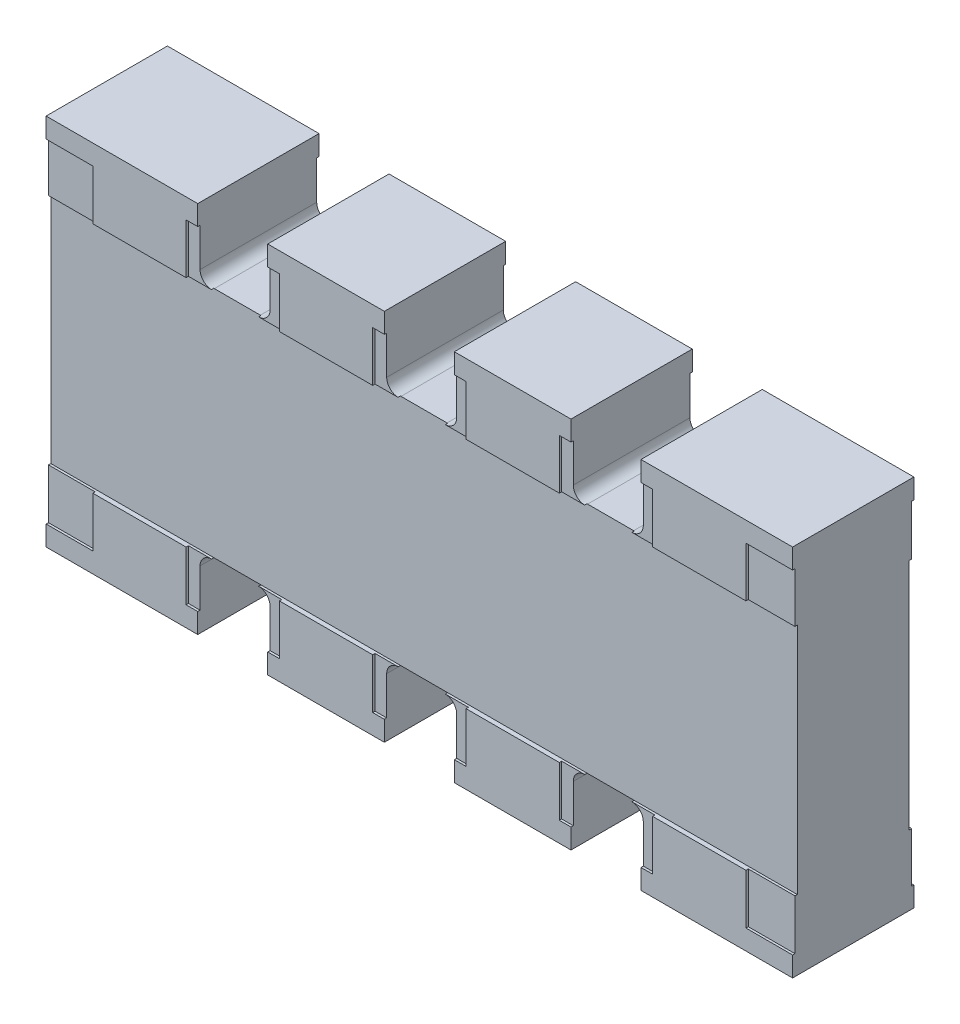
from build123d import *

# Parameters (mm, degrees)
SKETCH1_W           = 3.2
SKETCH1_H           = 1.6
BOSS_EXTRUDE1_DEPTH = 0.5
CUT_EXTRUDE1_DEPTH  = 1.5
SKETCH3_W           = 3.2
SKETCH3_H           = 1
CUT_EXTRUDE2_DEPTH  = 0.01
BOSS_EXTRUDE2_DEPTH = 0.01


with BuildPart() as part:
    # Sketch1 → Boss-Extrude1 (new body)
    with BuildSketch(Plane.XY):
        Rectangle(SKETCH1_W, SKETCH1_H)
    extrude(amount=BOSS_EXTRUDE1_DEPTH)

    # Sketch2 → Cut-Extrude1 (cut, through all)
    with BuildSketch(Plane(origin=(0, 0, 0), x_dir=(-1, 0, 0), z_dir=(0, 0, -1))):
        with BuildLine():
            Line((-0.15, 0.8), (0.15, 0.8))
            Line((0.15, 0.8), (0.15, 0.549979938))
            ThreePointArc((0.15, 0.549979938), (0.134862042, 0.514138446), (0.098614632, 0.5))
            Line((0.098614632, 0.5), (-0.098614632, 0.5))
            ThreePointArc((-0.098614632, 0.5), (-0.134862042, 0.514138446), (-0.15, 0.549979938))
            Line((-0.15, 0.549979938), (-0.15, 0.8))
        make_face()
        with BuildLine():
            Line((-0.65, 0.8), (-0.65, 0.549979938))
            ThreePointArc((-0.65, 0.549979938), (-0.665137958, 0.514138446), (-0.701385368, 0.5))
            Line((-0.701385368, 0.5), (-0.898614632, 0.5))
            ThreePointArc((-0.898614632, 0.5), (-0.934862042, 0.514138446), (-0.95, 0.549979938))
            Line((-0.95, 0.549979938), (-0.95, 0.8))
            Line((-0.95, 0.8), (-0.65, 0.8))
        make_face()
        with BuildLine():
            Line((0.95, 0.8), (0.65, 0.8))
            Line((0.65, 0.8), (0.65, 0.549979938))
            ThreePointArc((0.65, 0.549979938), (0.665137958, 0.514138446), (0.701385368, 0.5))
            Line((0.701385368, 0.5), (0.898614632, 0.5))
            ThreePointArc((0.898614632, 0.5), (0.934862042, 0.514138446), (0.95, 0.549979938))
            Line((0.95, 0.549979938), (0.95, 0.8))
        make_face()
        with BuildLine():
            Line((0.65, -0.8), (0.65, -0.549979938))
            ThreePointArc((0.65, -0.549979938), (0.665137958, -0.514138446), (0.701385368, -0.5))
            Line((0.701385368, -0.5), (0.898614632, -0.5))
            ThreePointArc((0.898614632, -0.5), (0.934862042, -0.514138446), (0.95, -0.549979938))
            Line((0.95, -0.549979938), (0.95, -0.8))
            Line((0.95, -0.8), (0.65, -0.8))
        make_face()
        with BuildLine():
            Line((0.15, -0.8), (0.15, -0.549979938))
            ThreePointArc((0.15, -0.549979938), (0.134862042, -0.514138446), (0.098614632, -0.5))
            Line((0.098614632, -0.5), (-0.098614632, -0.5))
            ThreePointArc((-0.098614632, -0.5), (-0.134862042, -0.514138446), (-0.15, -0.549979938))
            Line((-0.15, -0.549979938), (-0.15, -0.8))
            Line((-0.15, -0.8), (0.15, -0.8))
        make_face()
        with BuildLine():
            Line((-0.95, -0.8), (-0.65, -0.8))
            Line((-0.65, -0.8), (-0.65, -0.549979938))
            ThreePointArc((-0.65, -0.549979938), (-0.665137958, -0.514138446), (-0.701385368, -0.5))
            Line((-0.701385368, -0.5), (-0.898614632, -0.5))
            ThreePointArc((-0.898614632, -0.5), (-0.934862042, -0.514138446), (-0.95, -0.549979938))
            Line((-0.95, -0.549979938), (-0.95, -0.8))
        make_face()
    extrude(amount=-CUT_EXTRUDE1_DEPTH, mode=Mode.SUBTRACT)

    # Sketch3 → Cut-Extrude2 (cut)
    with BuildSketch(Plane(origin=(0, 0, 0), x_dir=(-1, 0, 0), z_dir=(0, 0, -1))):
        Rectangle(SKETCH3_W, SKETCH3_H)
    cut_extrude2 = extrude(amount=-CUT_EXTRUDE2_DEPTH, mode=Mode.SUBTRACT)

    # Mirror1: Cut-Extrude2 across plane
    add(cut_extrude2.mirror(Plane(origin=(0, 0, 0.25), x_dir=(1, 0, 0), z_dir=(0, 0, -1))), mode=Mode.SUBTRACT)

    # Sketch4 → Boss-Extrude2 (add)
    with BuildSketch(Plane(origin=(0, 0, 0), x_dir=(-1, 0, 0), z_dir=(0, 0, -1))):
        Polygon((-0.65, 0.71450836), (-0.6, 0.71450836), (-0.6, 0.5), (-0.2, 0.5), (-0.2, 0.71450836), (-0.15, 0.71450836), (-0.15, 0.8), (-0.65, 0.8), align=None)
        Polygon((-1.45, 0.71450836), (-1.4, 0.71450836), (-1.4, 0.5), (-1, 0.5), (-1, 0.71450836), (-0.95, 0.71450836), (-0.95, 0.8), (-1.45, 0.8), (-1.6, 0.8), (-1.6, 0.71450836), align=None)
        Polygon((1.6, 0.8), (1.6, 0.71450836), (1.45, 0.71450836), (1.4, 0.71450836), (1.4, 0.5), (1, 0.5), (1, 0.71450836), (0.95, 0.71450836), (0.95, 0.8), (1.45, 0.8), align=None)
        Polygon((0.6, 0.5), (0.2, 0.5), (0.2, 0.71450836), (0.15, 0.71450836), (0.15, 0.8), (0.65, 0.8), (0.65, 0.71450836), (0.6, 0.71450836), align=None)
        Polygon((1.45, -0.71450836), (1.4, -0.71450836), (1.4, -0.5), (1, -0.5), (1, -0.71450836), (0.95, -0.71450836), (0.95, -0.8), (1.45, -0.8), (1.6, -0.8), (1.6, -0.71450836), align=None)
        Polygon((-1.6, -0.8), (-1.6, -0.71450836), (-1.45, -0.71450836), (-1.4, -0.71450836), (-1.4, -0.5), (-1, -0.5), (-1, -0.71450836), (-0.95, -0.71450836), (-0.95, -0.8), (-1.45, -0.8), align=None)
        Polygon((0.65, -0.71450836), (0.6, -0.71450836), (0.6, -0.5), (0.2, -0.5), (0.2, -0.71450836), (0.15, -0.71450836), (0.15, -0.8), (0.65, -0.8), align=None)
        Polygon((-0.6, -0.5), (-0.2, -0.5), (-0.2, -0.71450836), (-0.15, -0.71450836), (-0.15, -0.8), (-0.65, -0.8), (-0.65, -0.71450836), (-0.6, -0.71450836), align=None)
    boss_extrude2 = extrude(amount=BOSS_EXTRUDE2_DEPTH)

    # Mirror2: Boss-Extrude2 across plane
    add(boss_extrude2.mirror(Plane(origin=(0, 0, 0.25), x_dir=(1, 0, 0), z_dir=(0, 0, -1))))


solid = part.part
